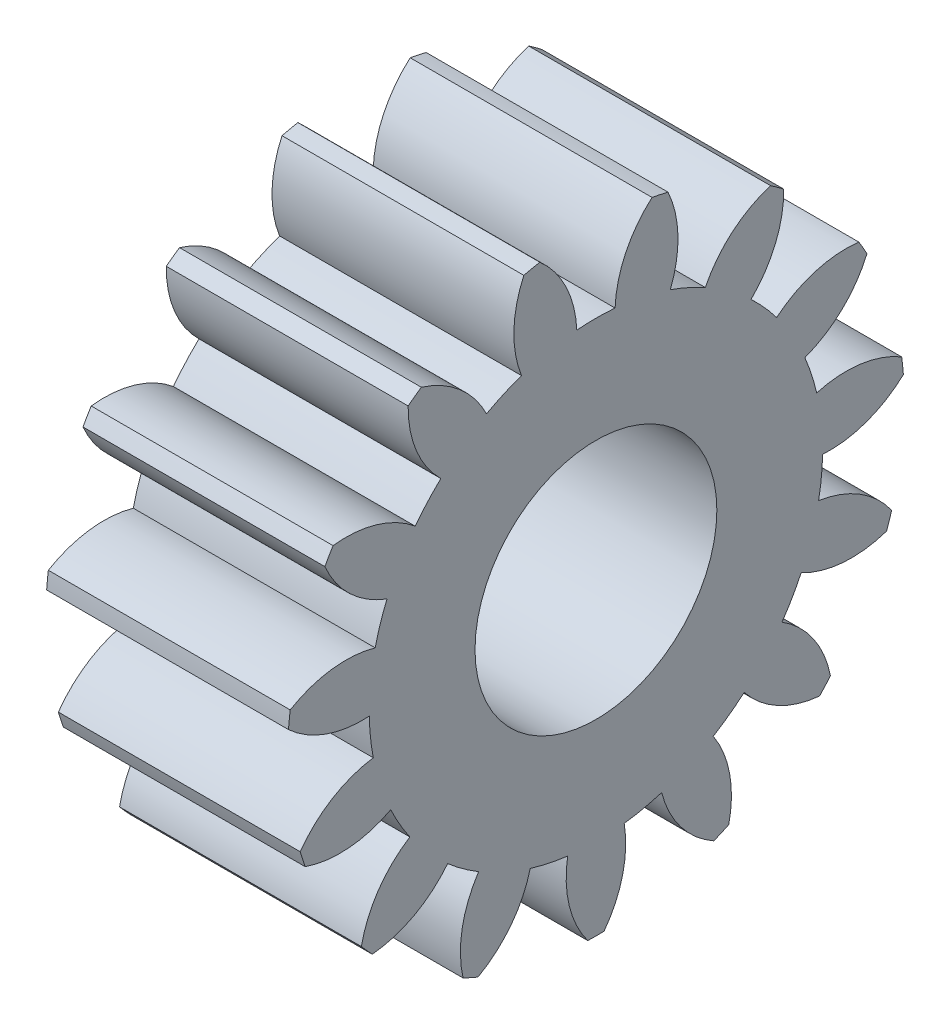
from build123d import *

# Parameters (mm, degrees)
BASPROSKE_W     = 10
BASPROSKE_H     = 12.75
TOOTHCUT_DEPTH  = 21.618559601
TEETHCUTS_COUNT = 15
TEETHCUTS_ANGLE = 336
BORSKE_R        = 5
BORE_DEPTH      = 50.0000508


with BuildPart() as part:
    # BasProSke → Base-Revolve (revolve)
    with BuildSketch(Plane(origin=(0, 0, 0), x_dir=(1, 0, 0), z_dir=(0, 1, 0)), mode=Mode.PRIVATE) as base_revolve_sk:
        with Locations((5, 6.375)):
            Rectangle(BASPROSKE_W, BASPROSKE_H)
    revolve(base_revolve_sk.sketch.rotate(Axis((-10, 0, 0), (1, 0, 0)), 180), axis=Axis((-10, 0, 0), (1, 0, 0)))

    # TooCutSke → ToothCut (cut, through all)
    with BuildSketch(Plane(origin=(0, 0, 0), x_dir=(0, 0, -1), z_dir=(1, 0, 0))):
        with BuildLine():
            ThreePointArc((0.791546546, 9.340520867), (0, 9.374), (-0.791546546, 9.340520867))
            ThreePointArc((-0.791546546, 9.340520867), (-1.235070734, 11.110218102), (-2.344732916, 12.558386549))
            ThreePointArc((-2.344732916, 12.558386549), (0, 12.7754), (2.344732916, 12.558386549))
            ThreePointArc((2.344732916, 12.558386549), (1.235070734, 11.110218102), (0.791546546, 9.340520867))
        make_face()
    toothcut = extrude(amount=TOOTHCUT_DEPTH, mode=Mode.SUBTRACT)

    # TeethCuts: ToothCut ×15 about axis
    teethcuts_axis = Axis((-10, 0, 0), (1, 0, 0))
    for i in range(1, TEETHCUTS_COUNT):
        add(toothcut.rotate(teethcuts_axis, i * TEETHCUTS_ANGLE / (TEETHCUTS_COUNT - 1)), mode=Mode.SUBTRACT)

    # BorSke → Bore (cut, symmetric)
    with BuildSketch(Plane(origin=(0, 0, 0), x_dir=(0, 0, -1), z_dir=(1, 0, 0))):
        with Locations(Location((0, 0, 0), (0, 0, 180))):
            Circle(BORSKE_R)
    extrude(amount=BORE_DEPTH, both=True, mode=Mode.SUBTRACT)


solid = part.part
